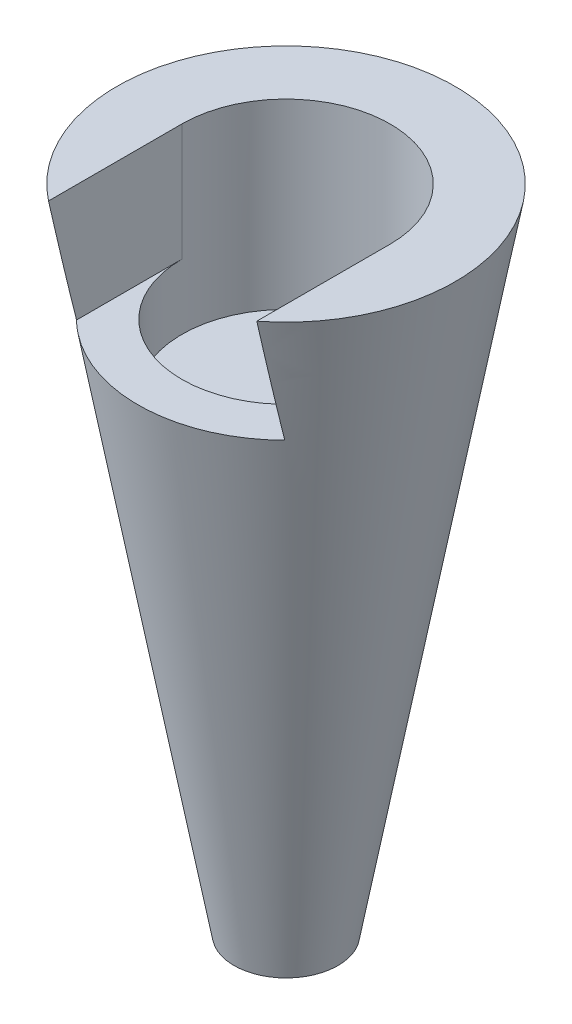
from build123d import *

# Parameters (mm, degrees)
SKETCH2_W          = 4.5
SKETCH2_H          = 3
CUT_EXTRUDE1_DEPTH = 6
SKETCH3_R          = 1.15
CUT_EXTRUDE2_DEPTH = 6
CUT_EXTRUDE3_DEPTH = 9
SKETCH5_R          = 8
CUT_EXTRUDE4_DEPTH = 5


with BuildPart() as part:
    # Sketch1 → Revolve1 (revolve)
    with BuildSketch(Plane.XY):
        Polygon((0, 50), (-13, 50), (-4, 0), (0, 0), align=None)
    revolve(axis=Axis((0, 0, 0), (0, 1, 0)))

    # Sketch2 → Cut-Extrude1 (cut)
    with BuildSketch(Plane.XZ):
        Rectangle(SKETCH2_W, SKETCH2_H)
    extrude(amount=-CUT_EXTRUDE1_DEPTH, mode=Mode.SUBTRACT)

    # Sketch3 → Cut-Extrude2 (cut)
    with BuildSketch(Plane.XY.offset(-1.5)):
        with Locations((0, 3.5)):
            Circle(SKETCH3_R)
    extrude(amount=-CUT_EXTRUDE2_DEPTH, mode=Mode.SUBTRACT)

    # Sketch4 → Cut-Extrude3 (cut)
    with BuildSketch(Plane(origin=(0, 50, 0), x_dir=(1, 0, 0), z_dir=(0, 1, 0))):
        with BuildLine():
            Line((-8, 0), (-8, -14.002606367))
            Line((-8, -14.002606367), (8, -14.002606367))
            Line((8, -14.002606367), (8, 0))
            ThreePointArc((8, 0), (0, 8), (-8, 0))
        make_face()
    extrude(amount=-CUT_EXTRUDE3_DEPTH, mode=Mode.SUBTRACT)

    # Sketch5 → Cut-Extrude4 (cut)
    with BuildSketch(Plane(origin=(0, 41, 0), x_dir=(1, 0, 0), z_dir=(0, 1, 0))):
        Circle(SKETCH5_R)
    extrude(amount=-CUT_EXTRUDE4_DEPTH, mode=Mode.SUBTRACT)


solid = part.part
